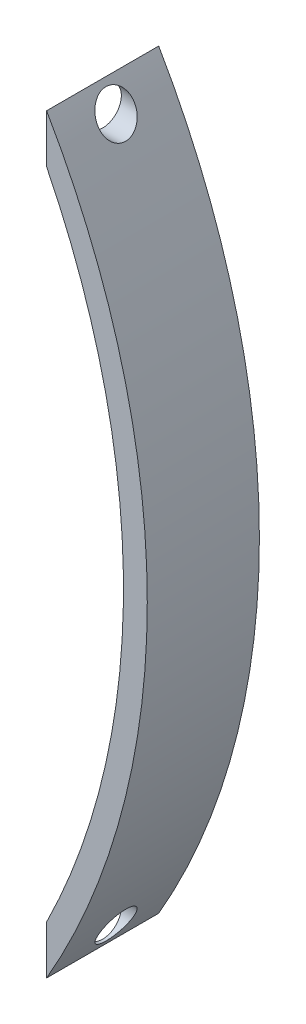
from build123d import *

# Parameters (mm, degrees)
BOSS_EXTRUDE1_DEPTH = 15
CUT_EXTRUDE1_REACH  = 15.469
SKETCH2_R           = 2.5


with BuildPart() as part:
    # Sketch1 → Boss-Extrude1 (new body)
    with BuildSketch(Plane.XY):
        with BuildLine():
            Line((0, 0), (0, 6.5))
            ThreePointArc((0, 6.5), (10.284515004, 50.25), (0, 94))
            Line((0, 94), (0, 100.5))
            ThreePointArc((0, 100.5), (13.469469939, 50.25), (0, 0))
        make_face()
    extrude(amount=BOSS_EXTRUDE1_DEPTH)

    # Sketch2 → Cut-Extrude1 (cut, up to next)
    with BuildSketch(Plane.ZY, mode=Mode.PRIVATE) as cut_extrude1_sk1:
        with Locations((7.5, 97.25)):
            Circle(SKETCH2_R)
    cut_extrude1_tool1 = extrude(cut_extrude1_sk1.sketch, amount=-CUT_EXTRUDE1_REACH, mode=Mode.PRIVATE) & part.part
    add(cut_extrude1_tool1.solids().sort_by_distance((0, 97.25, 7.5))[0], mode=Mode.SUBTRACT)
    # Sketch2 → Cut-Extrude1 (cut, up to next)
    with BuildSketch(Plane.ZY, mode=Mode.PRIVATE) as cut_extrude1_sk2:
        with Locations((7.5, 3.25)):
            Circle(SKETCH2_R)
    cut_extrude1_tool2 = extrude(cut_extrude1_sk2.sketch, amount=-CUT_EXTRUDE1_REACH, mode=Mode.PRIVATE) & part.part
    add(cut_extrude1_tool2.solids().sort_by_distance((0, 3.25, 7.5))[0], mode=Mode.SUBTRACT)


solid = part.part
